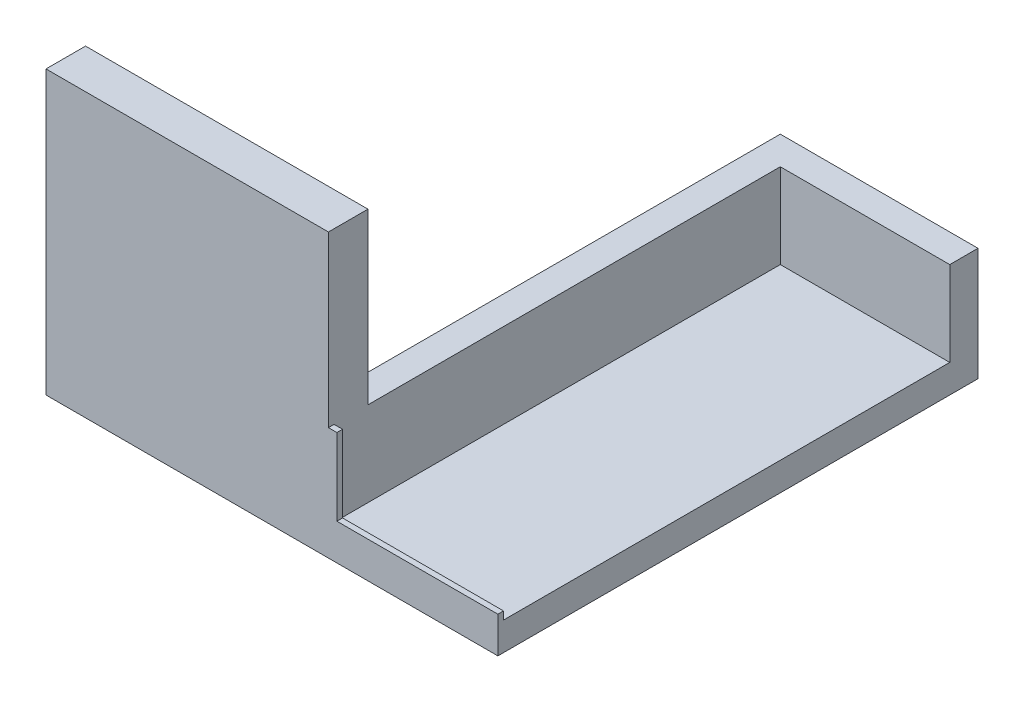
from build123d import *

# Parameters (mm, degrees)
BOSS_EXTRUDE1_DEPTH = 5
BOSS_EXTRUDE2_DEPTH = 20
BOSS_EXTRUDE3_DEPTH = 50
SKETCH2_W           = 28.5
SKETCH2_H           = 1
BOSS_EXTRUDE4_DEPTH = 1.4
SKETCH2_3_W         = 1.5
SKETCH2_3_H         = 1
BOSS_EXTRUDE5_DEPTH = 15


with BuildPart() as part:
    # Sketch1 → Boss-Extrude1 (new body)
    with BuildSketch(Plane(origin=(0, 0, 0), x_dir=(1, 0, 0), z_dir=(0, 1, 0))):
        Polygon((0, 80), (-30, 80), (-30, 7), (-30, 0), (0, 0), align=None)
    extrude(amount=BOSS_EXTRUDE1_DEPTH)

    # Sketch1_3 → Boss-Extrude2 (add)
    with BuildSketch(Plane(origin=(0, 0, 0), x_dir=(1, 0, 0), z_dir=(0, 1, 0))):
        Polygon((-35, 85), (-35, 7), (-30, 7), (-30, 80), (0, 80), (0, 85), align=None)
    extrude(amount=BOSS_EXTRUDE2_DEPTH)

    # Sketch1_4 → Boss-Extrude3 (add)
    with BuildSketch(Plane(origin=(0, 0, 0), x_dir=(1, 0, 0), z_dir=(0, 1, 0))):
        Polygon((-30, 0), (-30, 7), (-35, 7), (-80, 7), (-80, 0), align=None)
    extrude(amount=BOSS_EXTRUDE3_DEPTH)

    # Sketch2 → Boss-Extrude4 (add)
    with BuildSketch(Plane(origin=(0, 5, 0), x_dir=(1, 0, 0), z_dir=(0, 1, 0))):
        with Locations((-14.25, 0.5)):
            Rectangle(SKETCH2_W, SKETCH2_H)
    extrude(amount=BOSS_EXTRUDE4_DEPTH)

    # Sketch2_3 → Boss-Extrude5 (add)
    with BuildSketch(Plane(origin=(0, 5, 0), x_dir=(1, 0, 0), z_dir=(0, 1, 0))):
        with Locations((-29.25, 0.5)):
            Rectangle(SKETCH2_3_W, SKETCH2_3_H)
    extrude(amount=BOSS_EXTRUDE5_DEPTH)


solid = part.part
